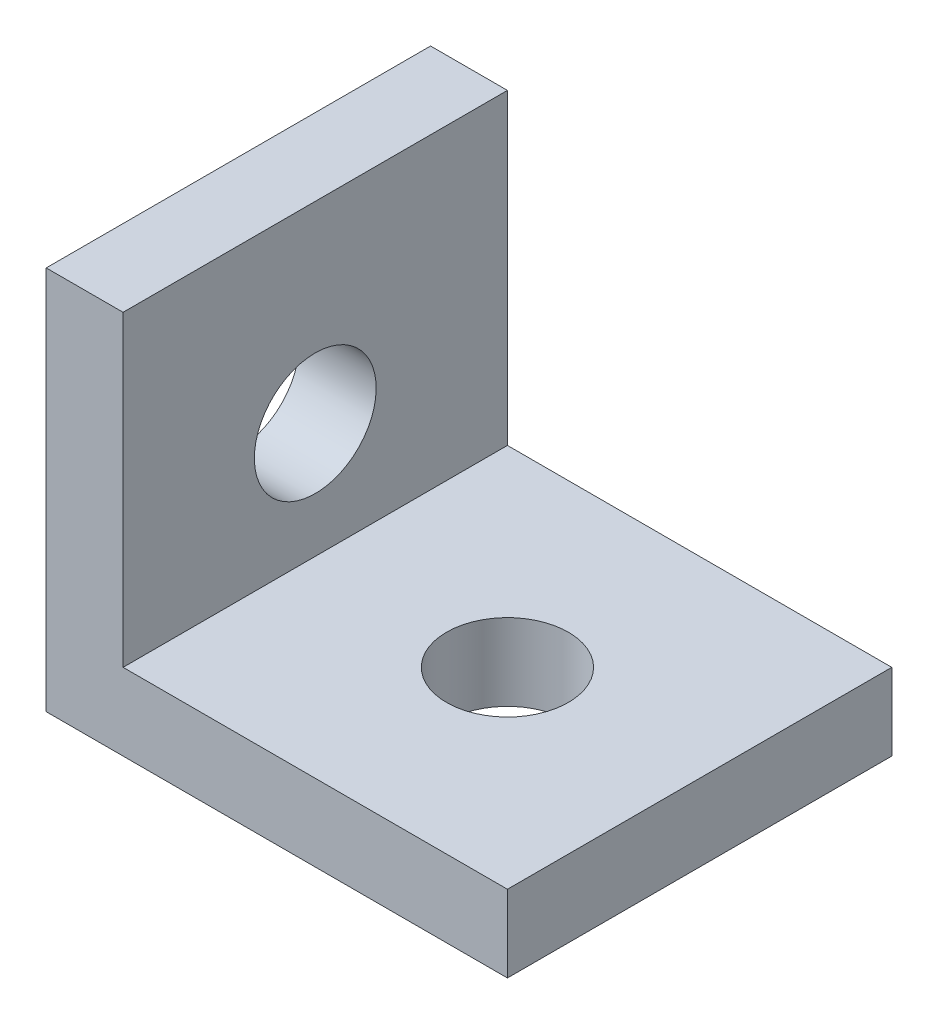
from build123d import *

# Parameters (mm, degrees)
BOSS_EXTRUDE1_DEPTH = 10
SKETCH2_R           = 1.585
CUT_EXTRUDE1_DEPTH  = 3
SKETCH3_R           = 1.585
CUT_EXTRUDE2_DEPTH  = 3


with BuildPart() as part:
    # Sketch1 → Boss-Extrude1 (new body)
    with BuildSketch(Plane.XY):
        Polygon((0, 0), (12, 0), (12, 2), (2, 2), (2, 10), (0, 10), align=None)
    extrude(amount=BOSS_EXTRUDE1_DEPTH)

    # Sketch2 → Cut-Extrude1 (cut, through all)
    with BuildSketch(Plane(origin=(0, 2, 0), x_dir=(1, 0, 0), z_dir=(0, 1, 0))):
        with Locations((7, -5)):
            Circle(SKETCH2_R)
    extrude(amount=-CUT_EXTRUDE1_DEPTH, mode=Mode.SUBTRACT)

    # Sketch3 → Cut-Extrude2 (cut, through all)
    with BuildSketch(Plane(origin=(2, 0, 0), x_dir=(0, 0, -1), z_dir=(1, 0, 0))):
        with Locations((-5, 5)):
            Circle(SKETCH3_R)
    extrude(amount=-CUT_EXTRUDE2_DEPTH, mode=Mode.SUBTRACT)


solid = part.part
